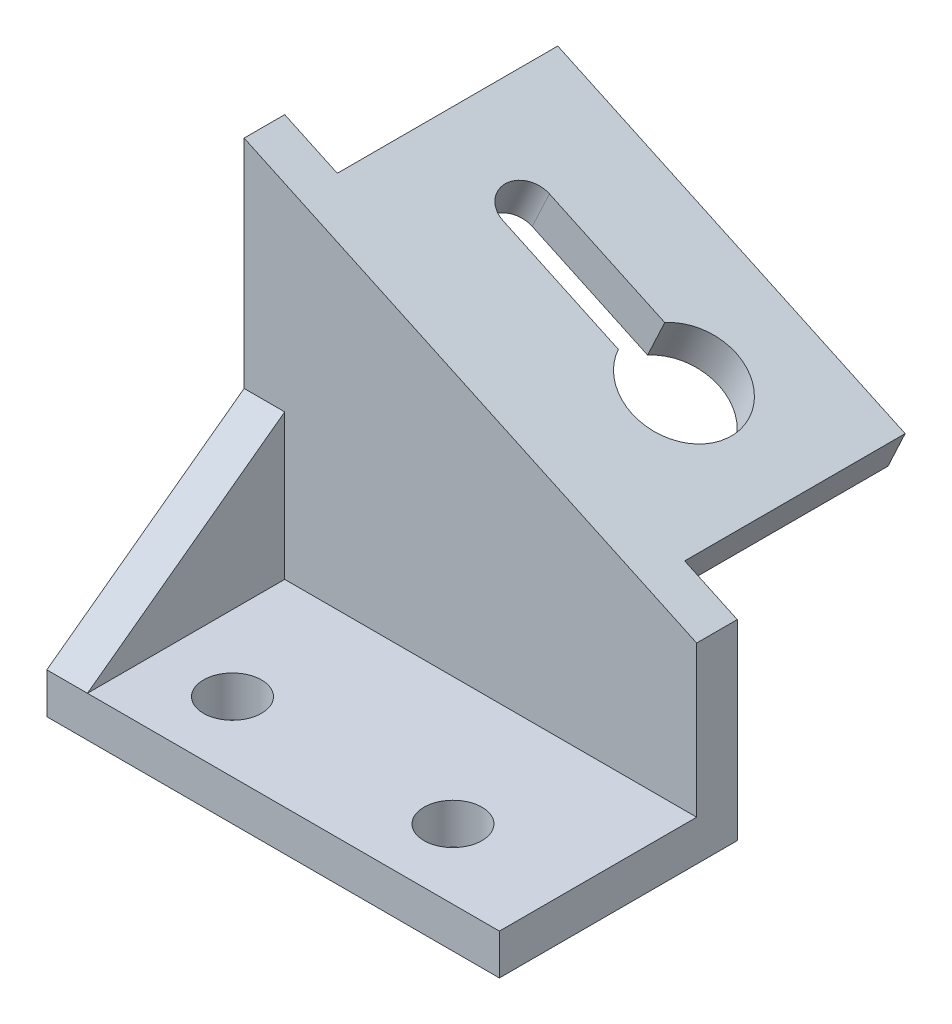
from build123d import *

# Parameters (mm, degrees)
BOSS_EXTRUDE1_DEPTH = 7
BOSS_EXTRUDE2_DEPTH = 38
CUT_EXTRUDE1_DEPTH  = 48
SKETCH4_W           = 78
SKETCH4_H           = 7
BOSS_EXTRUDE3_DEPTH = 34
BOSS_EXTRUDE4_DEPTH = 7
SKETCH6_R           = 5
CUT_EXTRUDE2_DEPTH  = 21


with BuildPart() as part:
    # Sketch1 → Boss-Extrude1 (new body)
    with BuildSketch(Plane.XY):
        Polygon((39, 16.5), (-39, 52.871997336), (-39, 16.5), (-39, -16.5), (39, -16.5), align=None)
    extrude(amount=BOSS_EXTRUDE1_DEPTH)

    # Sketch2 → Boss-Extrude2 (add)
    with BuildSketch(Plane(origin=(0, 0, 0), x_dir=(-1, 0, 0), z_dir=(0, 0, -1))):
        Polygon((-29.93692213, 20.726182617), (29.93692213, 48.645814719), (32.895249962, 42.301660209), (-26.978594297, 14.382028108), align=None)
    extrude(amount=BOSS_EXTRUDE2_DEPTH)

    # Sketch3 → Cut-Extrude1 (cut)
    with BuildSketch(Plane(origin=(13.285508267, 28.490864421, 0), x_dir=(0.906307787, -0.422618262, 0), z_dir=(0.422618262, 0.906307787, 0))):
        with BuildLine():
            Line((-31.627197624, 22), (-9.689455373, 22))
            ThreePointArc((-9.689455373, 22), (7.372802376, 18), (-9.689455373, 14))
            Line((-9.689455373, 14), (-31.627197624, 14))
            ThreePointArc((-31.627197624, 14), (-35.627197624, 18), (-31.627197624, 22))
        make_face()
    extrude(amount=-CUT_EXTRUDE1_DEPTH, mode=Mode.SUBTRACT)

    # Sketch4 → Boss-Extrude3 (add)
    with BuildSketch(Plane.XY.offset(7)):
        with Locations((0, -13)):
            Rectangle(SKETCH4_W, SKETCH4_H)
    extrude(amount=BOSS_EXTRUDE3_DEPTH)

    # Sketch5 → Boss-Extrude4 (add)
    with BuildSketch(Plane.ZY.offset(39)):
        Polygon((7, -9.5), (7, 15.5), (41, -9.5), align=None)
    extrude(amount=-BOSS_EXTRUDE4_DEPTH)

    # Sketch6 → Cut-Extrude2 (cut)
    with BuildSketch(Plane(origin=(0, -9.5, 0), x_dir=(1, 0, 0), z_dir=(0, 1, 0))):
        with Locations((-19, -29)):
            Circle(SKETCH6_R)
        with Locations((19, -29)):
            Circle(SKETCH6_R)
    extrude(amount=-CUT_EXTRUDE2_DEPTH, mode=Mode.SUBTRACT)


solid = part.part
